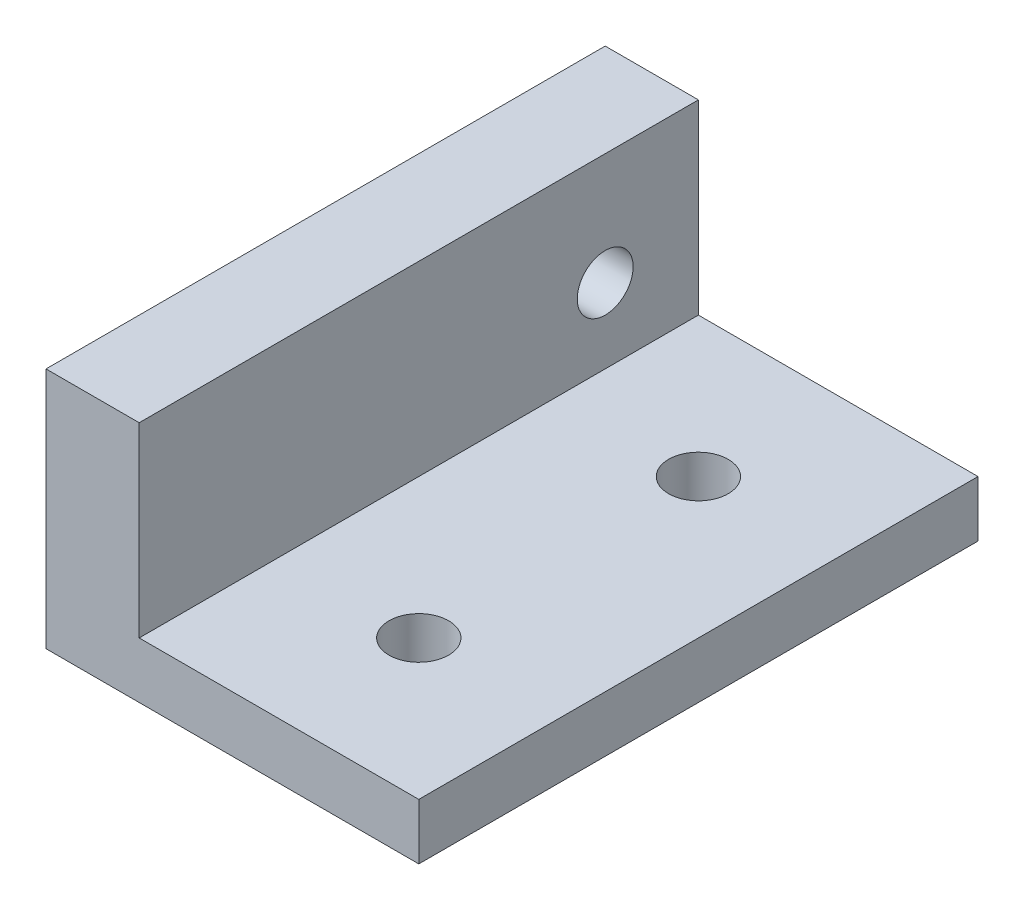
from build123d import *

# Parameters (mm, degrees)
SKETCH1_W           = 20
SKETCH1_H           = 30
BOSS_EXTRUDE1_DEPTH = 3
SKETCH2_W           = 5
SKETCH2_H           = 30
BOSS_EXTRUDE2_DEPTH = 10
SKETCH3_R           = 1.5
CUT_EXTRUDE1_DEPTH  = 10
SKETCH4_R           = 1.6
CUT_EXTRUDE2_DEPTH  = 4


with BuildPart() as part:
    # Sketch1 → Boss-Extrude1 (new body)
    with BuildSketch(Plane(origin=(0, 0, 0), x_dir=(1, 0, 0), z_dir=(0, 1, 0))):
        Rectangle(SKETCH1_W, SKETCH1_H)
    extrude(amount=BOSS_EXTRUDE1_DEPTH)

    # Sketch2 → Boss-Extrude2 (add)
    with BuildSketch(Plane(origin=(0, 3, 0), x_dir=(1, 0, 0), z_dir=(0, 1, 0))):
        with Locations((-7.5, 0)):
            Rectangle(SKETCH2_W, SKETCH2_H)
    extrude(amount=BOSS_EXTRUDE2_DEPTH)

    # Sketch3 → Cut-Extrude1 (cut)
    with BuildSketch(Plane.ZY.offset(10)):
        with Locations((-10, 7)):
            Circle(SKETCH3_R)
    extrude(amount=-CUT_EXTRUDE1_DEPTH, mode=Mode.SUBTRACT)

    # Sketch4 → Cut-Extrude2 (cut, through all)
    with BuildSketch(Plane(origin=(0, 3, 0), x_dir=(1, 0, 0), z_dir=(0, 1, 0))):
        with Locations((2.5, -7.5)):
            Circle(SKETCH4_R)
        with Locations((2.5, 7.5)):
            Circle(SKETCH4_R)
    extrude(amount=-CUT_EXTRUDE2_DEPTH, mode=Mode.SUBTRACT)


solid = part.part
